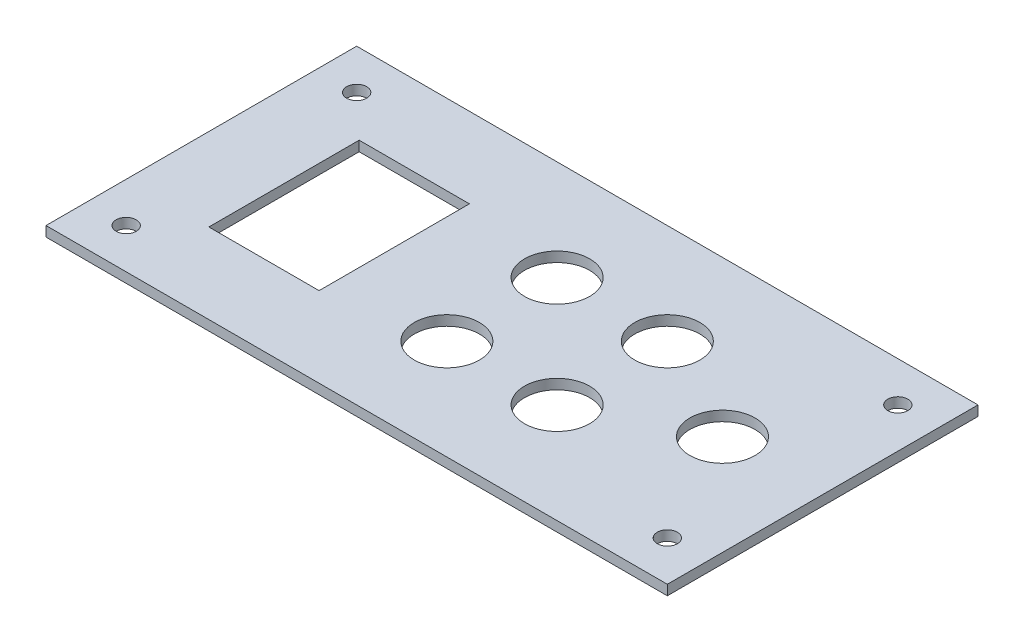
from build123d import *

# Parameters (mm, degrees)
SKETCH1_W           = 124
SKETCH1_H           = 62
SKETCH1_R           = 6.5
SKETCH1_R_2         = 2
SKETCH1_W_2         = 22
SKETCH1_H_2         = 30
BOSS_EXTRUDE1_DEPTH = 2


with BuildPart() as part:
    # Sketch1 → Boss-Extrude1 (new body)
    with BuildSketch(Plane(origin=(0, 0, 0), x_dir=(1, 0, 0), z_dir=(0, 1, 0))):
        with Locations((14.5, 0)):
            Rectangle(SKETCH1_W, SKETCH1_H)
        with Locations((12.5, 11)):
            Circle(SKETCH1_R, mode=Mode.SUBTRACT)
        with Locations((12.5, -11)):
            Circle(SKETCH1_R, mode=Mode.SUBTRACT)
        with Locations((34.5, 11)):
            Circle(SKETCH1_R, mode=Mode.SUBTRACT)
        with Locations((34.5, -11)):
            Circle(SKETCH1_R, mode=Mode.SUBTRACT)
        with Locations((56.5, 0)):
            Circle(SKETCH1_R, mode=Mode.SUBTRACT)
        with Locations((-39.5, 23)):
            Circle(SKETCH1_R_2, mode=Mode.SUBTRACT)
        with Locations((68.5, 23)):
            Circle(SKETCH1_R_2, mode=Mode.SUBTRACT)
        with Locations((68.5, -23)):
            Circle(SKETCH1_R_2, mode=Mode.SUBTRACT)
        with Locations((-39.5, -23)):
            Circle(SKETCH1_R_2, mode=Mode.SUBTRACT)
        with Locations((-20, 0)):
            Rectangle(SKETCH1_W_2, SKETCH1_H_2, mode=Mode.SUBTRACT)
    extrude(amount=BOSS_EXTRUDE1_DEPTH)


solid = part.part
